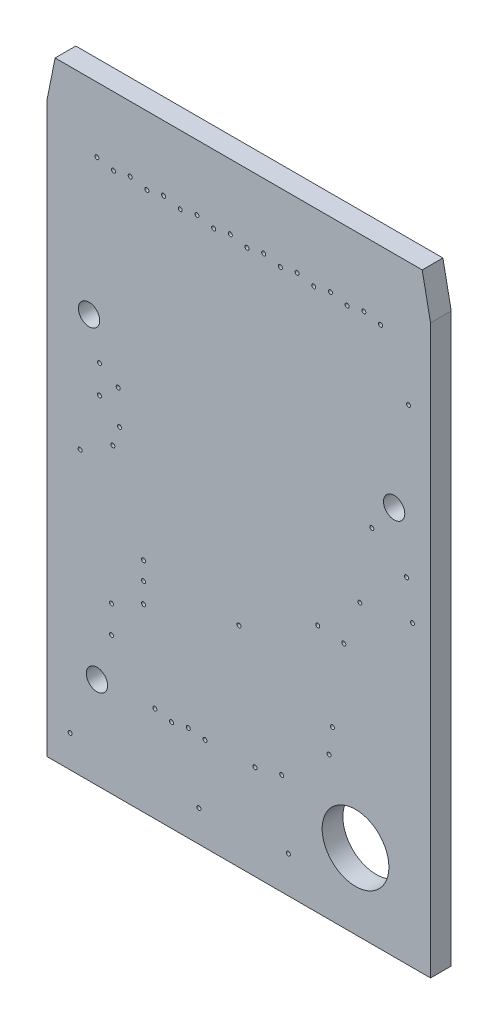
from build123d import *

# Parameters (mm, degrees)
BOARD_OUTLINE_DEPTH = 0.7874
SKETCH2_R           = 0.0762
NPTH_DEPTH          = 1.7874
SKETCH3_R           = 0.405
SKETCH3_R_2         = 1.27
PTH_DEPTH           = 1.7874


with BuildPart() as part:
    # Sketch1 → Board_Outline (new body)
    with BuildSketch(Plane.XY):
        Polygon((14.605, 0), (0, 0), (0, 21.59), (0.3175, 23.1775), (14.2875, 23.1775), (14.605, 21.59), align=None)
    extrude(amount=BOARD_OUTLINE_DEPTH)

    # Sketch2 → NPTH (cut, through all)
    with BuildSketch(Plane.XY):
        with Locations((2.4638, 6.2738)):
            Circle(SKETCH2_R)
        with Locations((7.9248, 3.6068)):
            Circle(SKETCH2_R)
        with Locations((11.303, 9.3726)):
            Circle(SKETCH2_R)
        with Locations((10.3124, 9.4742)):
            Circle(SKETCH2_R)
        with Locations((13.7668, 18.4658)):
            Circle(SKETCH2_R)
        with Locations((1.27, 10.7442)):
            Circle(SKETCH2_R)
        with Locations((1.905, 20.701)):
            Circle(SKETCH2_R)
        with Locations((2.5146, 11.5062)):
            Circle(SKETCH2_R)
        with Locations((11.9126, 11.0236)):
            Circle(SKETCH2_R)
        with Locations((11.43, 20.574)):
            Circle(SKETCH2_R)
        with Locations((10.795, 20.701)):
            Circle(SKETCH2_R)
        with Locations((4.1148, 3.6322)):
            Circle(SKETCH2_R)
        with Locations((8.9408, 3.8608)):
            Circle(SKETCH2_R)
        with Locations((3.683, 8.3058)):
            Circle(SKETCH2_R)
        with Locations((4.7498, 3.5052)):
            Circle(SKETCH2_R)
        with Locations((12.065, 20.701)):
            Circle(SKETCH2_R)
        with Locations((10.16, 20.574)):
            Circle(SKETCH2_R)
        with Locations((9.525, 20.701)):
            Circle(SKETCH2_R)
        with Locations((8.89, 20.574)):
            Circle(SKETCH2_R)
        with Locations((10.7442, 5.4356)):
            Circle(SKETCH2_R)
        with Locations((3.683, 7.62)):
            Circle(SKETCH2_R)
        with Locations((9.1948, 1.397)):
            Circle(SKETCH2_R)
        with Locations((3.683, 6.858)):
            Circle(SKETCH2_R)
        with Locations((7.3152, 7.9756)):
            Circle(SKETCH2_R)
        with Locations((6.0198, 3.556)):
            Circle(SKETCH2_R)
        with Locations((5.3848, 3.6322)):
            Circle(SKETCH2_R)
        with Locations((8.255, 20.701)):
            Circle(SKETCH2_R)
        with Locations((7.62, 20.574)):
            Circle(SKETCH2_R)
        with Locations((6.985, 20.701)):
            Circle(SKETCH2_R)
        with Locations((6.35, 20.574)):
            Circle(SKETCH2_R)
        with Locations((5.715, 20.701)):
            Circle(SKETCH2_R)
        with Locations((5.08, 20.574)):
            Circle(SKETCH2_R)
        with Locations((4.445, 20.701)):
            Circle(SKETCH2_R)
        with Locations((3.81, 20.574)):
            Circle(SKETCH2_R)
        with Locations((3.175, 20.701)):
            Circle(SKETCH2_R)
        with Locations((2.54, 20.574)):
            Circle(SKETCH2_R)
        with Locations((2.0066, 13.97)):
            Circle(SKETCH2_R)
        with Locations((12.7, 20.574)):
            Circle(SKETCH2_R)
        with Locations((0.889, 1.2192)):
            Circle(SKETCH2_R)
        with Locations((13.6906, 12.7508)):
            Circle(SKETCH2_R)
        with Locations((2.0066, 12.9032)):
            Circle(SKETCH2_R)
        with Locations((12.3698, 13.716)):
            Circle(SKETCH2_R)
        with Locations((5.7912, 1.1938)):
            Circle(SKETCH2_R)
        with Locations((2.4638, 5.2324)):
            Circle(SKETCH2_R)
        with Locations((2.7178, 13.5128)):
            Circle(SKETCH2_R)
        with Locations((10.8712, 6.4008)):
            Circle(SKETCH2_R)
        with Locations((13.9192, 11.3538)):
            Circle(SKETCH2_R)
        with Locations((2.7686, 12.2428)):
            Circle(SKETCH2_R)
    extrude(amount=NPTH_DEPTH, mode=Mode.SUBTRACT)

    # Sketch3 → PTH (cut, through all)
    with BuildSketch(Plane.XY):
        with Locations((1.61, 15.37)):
            Circle(SKETCH3_R)
        with Locations((11.75, 2.86)):
            Circle(SKETCH3_R_2)
        with Locations((13.22, 14.81)):
            Circle(SKETCH3_R)
        with Locations((1.91, 3.49)):
            Circle(SKETCH3_R)
    extrude(amount=PTH_DEPTH, mode=Mode.SUBTRACT)


solid = part.part
